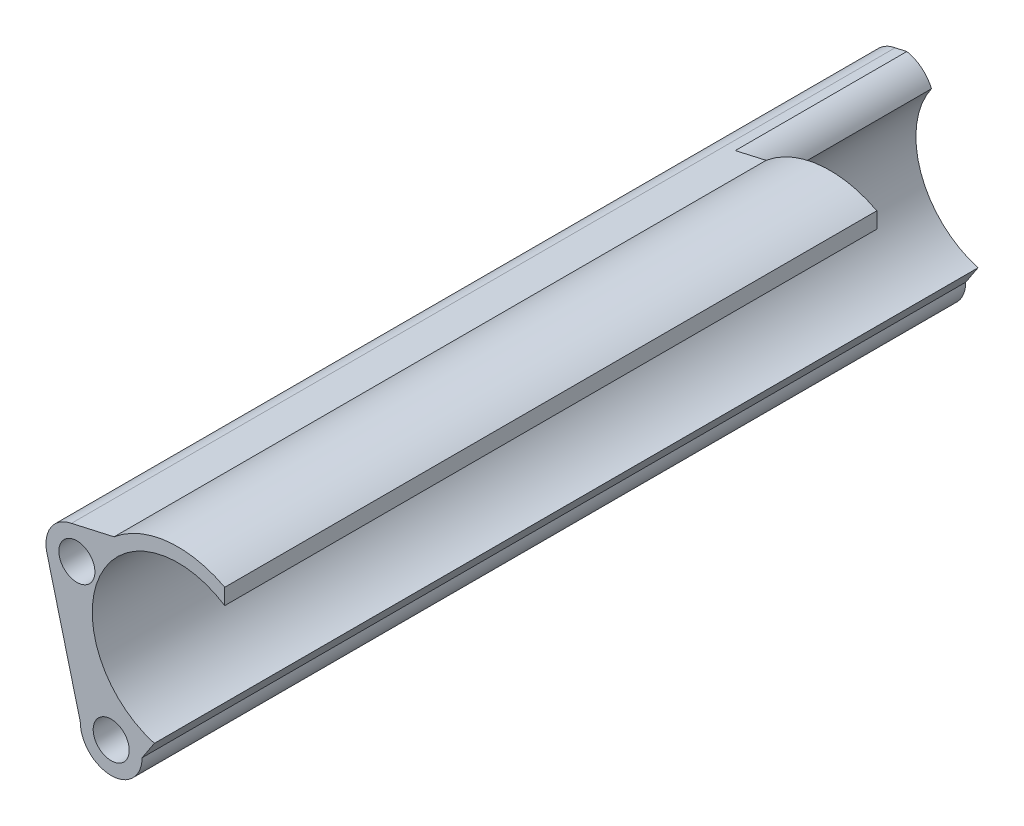
from build123d import *

# Parameters (mm, degrees)
ESQUISSE1_R             = 2.625
BOSS_EXTRU_1_DEPTH      = 120
ENL_V_MAT_EXTRU_1_DEPTH = 25


with BuildPart() as part:
    # Esquisse1 → Boss.-Extru.1 (new body)
    with BuildSketch(Plane.XY):
        with BuildLine():
            ThreePointArc((-0.79755539, 4.428758901), (-3.787637609, 2.429773929), (-4.358021192, -1.12145053))
            Line((-4.358021192, -1.12145053), (0.5, -20))
            ThreePointArc((0.5, -20), (5, -24.5), (9.5, -20))
            Line((9.5, -20), (11.28572177, -17.287605871))
            ThreePointArc((11.28572177, -17.287605871), (10.940890985, -17.183131081), (10.599214607, -17.068761049))
            ThreePointArc((10.599214607, -17.068761049), (2.237966256, -5.391928791), (10.376689651, 6.441078731))
            ThreePointArc((10.376689651, 6.441078731), (16.104400227, 7.151408987), (21.540678755, 5.212823607))
            Line((21.540678755, 5.212823607), (21.540678755, 7.531281515))
            ThreePointArc((21.540678755, 7.531281515), (13.221135766, 9.146884287), (5.419576542, 5.836198326))
            Line((5.419576542, 5.836198326), (-0.79755539, 4.428758901))
        make_face()
        with Locations((5, -20)):
            Circle(ESQUISSE1_R, mode=Mode.SUBTRACT)
        Circle(ESQUISSE1_R, mode=Mode.SUBTRACT)
    extrude(amount=BOSS_EXTRU_1_DEPTH)

    # Esquisse2 → Enlèv. mat.-Extru.1 (cut)
    with BuildSketch(Plane(origin=(0, 0, 0), x_dir=(-1, 0, 0), z_dir=(0, 0, -1))):
        with BuildLine():
            Line((-0.802648586, 4.838533405), (-23.542155856, 15.333417872))
            Line((-23.542155856, 15.333417872), (-23.542155856, 4.140650018))
            Line((-23.542155856, 4.140650018), (-4.513818825, 1.918616657))
            ThreePointArc((-4.513818825, 1.918616657), (-3.032768518, 3.854603141), (-0.802648586, 4.838533405))
        make_face()
    extrude(amount=-ENL_V_MAT_EXTRU_1_DEPTH, mode=Mode.SUBTRACT)


solid = part.part
